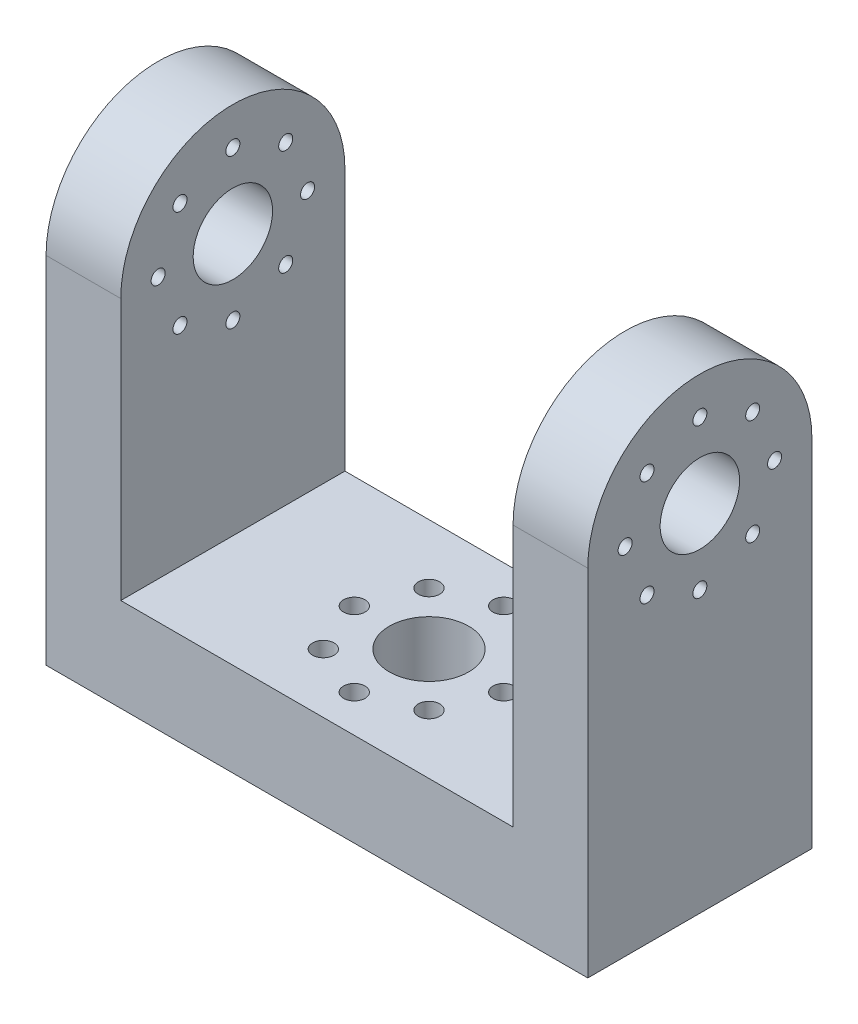
from build123d import *

# Parameters (mm, degrees)
DODANIE_WYCI_GNI_CIE1_DEPTH = 24
SZKIC2_R                    = 4.25
WYTNIJ_WYCI_GNI_CIE1_DEPTH  = 81.249610591
SZKIC3_R                    = 4.25
SZKIC3_R_2                  = 0.65
WYTNIJ_WYCI_GNI_CIE2_DEPTH  = 55.927224579
SZKIC4_R                    = 0.75
WYTNIJ_WYCI_GNI_CIE3_DEPTH  = 81.249610591
SZKIC3_3_R                  = 1.15
SZKIC3_3_R_2                = 0.65
WYTNIJ_WYCI_GNI_CIE4_DEPTH  = 4


with BuildPart() as part:
    # Szkic1 → Dodanie-wyci_gni_cie1 (new body)
    with BuildSketch(Plane.XY):
        Polygon((21, 10), (-21, 10), (-21, 50), (-29, 50), (-29, 0), (29, 0), (29, 50), (21, 50), align=None)
    extrude(amount=DODANIE_WYCI_GNI_CIE1_DEPTH)

    # Szkic2 → Wytnij-wyci_gni_cie1 (cut, through all)
    with BuildSketch(Plane(origin=(29, 0, 0), x_dir=(0, 0, -1), z_dir=(1, 0, 0))):
        with BuildLine():
            ThreePointArc((-12, 50), (-3.514718626, 46.485281374), (0, 38))
            Line((0, 38), (0, 50))
            Line((0, 50), (-12, 50))
        make_face()
        with BuildLine():
            ThreePointArc((-24, 38), (-20.485281374, 46.485281374), (-12, 50))
            Line((-12, 50), (-24, 50))
            Line((-24, 50), (-24, 38))
        make_face()
        with Locations((-12, 38)):
            Circle(SZKIC2_R)
    extrude(amount=-WYTNIJ_WYCI_GNI_CIE1_DEPTH, mode=Mode.SUBTRACT)

    # Szkic3 → Wytnij-wyci_gni_cie2 (cut, through all)
    with BuildSketch(Plane(origin=(0, 10, 0), x_dir=(1, 0, 0), z_dir=(0, 1, 0))):
        with Locations((0, -12)):
            Circle(SZKIC3_R)
        with Locations((5.656854249, -17.656854249)):
            Circle(SZKIC3_R_2)
        with Locations((8, -12)):
            Circle(SZKIC3_R_2)
        with Locations((0, -20)):
            Circle(SZKIC3_R_2)
        with Locations((-5.656854249, -17.656854249)):
            Circle(SZKIC3_R_2)
        with Locations((-8, -12)):
            Circle(SZKIC3_R_2)
        with Locations((-5.656854249, -6.343145751)):
            Circle(SZKIC3_R_2)
        with Locations((0, -4)):
            Circle(SZKIC3_R_2)
        with Locations((5.656854249, -6.343145751)):
            Circle(SZKIC3_R_2)
    extrude(amount=-WYTNIJ_WYCI_GNI_CIE2_DEPTH, mode=Mode.SUBTRACT)

    # Szkic4 → Wytnij-wyci_gni_cie3 (cut, through all)
    with BuildSketch(Plane.ZY.offset(29)):
        with Locations((4, 38)):
            Circle(SZKIC4_R)
        with Locations((12, 46)):
            Circle(SZKIC4_R)
        with Locations((20, 38)):
            Circle(SZKIC4_R)
        with Locations((12, 30)):
            Circle(SZKIC4_R)
        with Locations((6.343145751, 32.343145751)):
            Circle(SZKIC4_R)
        with Locations((6.343145751, 43.656854249)):
            Circle(SZKIC4_R)
        with Locations((17.656854249, 43.656854249)):
            Circle(SZKIC4_R)
        with Locations((17.656854249, 32.343145751)):
            Circle(SZKIC4_R)
    extrude(amount=-WYTNIJ_WYCI_GNI_CIE3_DEPTH, mode=Mode.SUBTRACT)

    # Szkic3_3 → Wytnij-wyci_gni_cie4 (cut)
    # profile 1 of 8: a face of its own
    with BuildSketch(Plane(origin=(0, 10, 0), x_dir=(1, 0, 0), z_dir=(0, 1, 0))):
        with Locations((8, -12)):
            Circle(SZKIC3_3_R)
        with Locations((8, -12)):
            Circle(SZKIC3_3_R_2, mode=Mode.SUBTRACT)
    # profile 2 of 8: a face of its own
    with BuildSketch(Plane(origin=(0, 10, 0), x_dir=(1, 0, 0), z_dir=(0, 1, 0))):
        with Locations((5.656854249, -17.656854249)):
            Circle(SZKIC3_3_R)
        with Locations((5.656854249, -17.656854249)):
            Circle(SZKIC3_3_R_2, mode=Mode.SUBTRACT)
    # profile 3 of 8: a face of its own
    with BuildSketch(Plane(origin=(0, 10, 0), x_dir=(1, 0, 0), z_dir=(0, 1, 0))):
        with Locations((0, -20)):
            Circle(SZKIC3_3_R)
        with Locations((0, -20)):
            Circle(SZKIC3_3_R_2, mode=Mode.SUBTRACT)
    # profile 4 of 8: a face of its own
    with BuildSketch(Plane(origin=(0, 10, 0), x_dir=(1, 0, 0), z_dir=(0, 1, 0))):
        with Locations((-5.656854249, -17.656854249)):
            Circle(SZKIC3_3_R)
        with Locations((-5.656854249, -17.656854249)):
            Circle(SZKIC3_3_R_2, mode=Mode.SUBTRACT)
    # profile 5 of 8: a face of its own
    with BuildSketch(Plane(origin=(0, 10, 0), x_dir=(1, 0, 0), z_dir=(0, 1, 0))):
        with Locations((-8, -12)):
            Circle(SZKIC3_3_R)
        with Locations((-8, -12)):
            Circle(SZKIC3_3_R_2, mode=Mode.SUBTRACT)
    # profile 6 of 8: a face of its own
    with BuildSketch(Plane(origin=(0, 10, 0), x_dir=(1, 0, 0), z_dir=(0, 1, 0))):
        with Locations((-5.656854249, -6.343145751)):
            Circle(SZKIC3_3_R)
        with Locations((-5.656854249, -6.343145751)):
            Circle(SZKIC3_3_R_2, mode=Mode.SUBTRACT)
    # profile 7 of 8: a face of its own
    with BuildSketch(Plane(origin=(0, 10, 0), x_dir=(1, 0, 0), z_dir=(0, 1, 0))):
        with Locations((0, -4)):
            Circle(SZKIC3_3_R)
        with Locations((0, -4)):
            Circle(SZKIC3_3_R_2, mode=Mode.SUBTRACT)
    # profile 8 of 8: a face of its own
    with BuildSketch(Plane(origin=(0, 10, 0), x_dir=(1, 0, 0), z_dir=(0, 1, 0))):
        with Locations((5.656854249, -6.343145751)):
            Circle(SZKIC3_3_R)
        with Locations((5.656854249, -6.343145751)):
            Circle(SZKIC3_3_R_2, mode=Mode.SUBTRACT)
    extrude(amount=-WYTNIJ_WYCI_GNI_CIE4_DEPTH, mode=Mode.SUBTRACT)


solid = part.part
